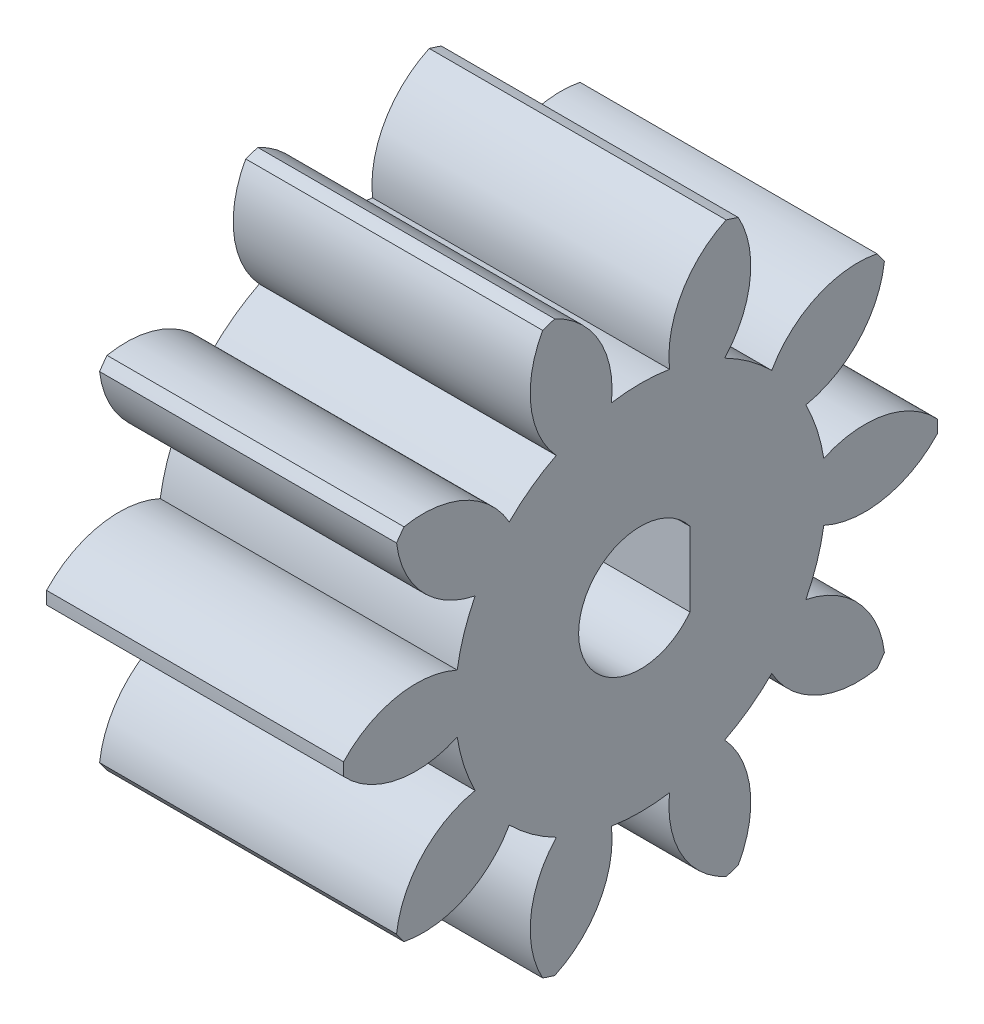
from build123d import *

# Parameters (mm, degrees)
SKETCH1_R           = 2.5
BOSS_EXTRUDE1_DEPTH = 12
BOSS_EXTRUDE2_DEPTH = 12


with BuildPart() as part:
    # Sketch1 → Boss-Extrude1 (new body)
    with BuildSketch(Plane(origin=(4.177782817, 0, 0), x_dir=(0, 0, -1), z_dir=(1, 0, 0))):
        with BuildLine():
            ThreePointArc((5.17160003, 0.862151985), (3.024281035, 2.061571734), (0.581113459, 1.777813393))
            ThreePointArc((0.581113459, 1.777813393), (0.306322633, 2.922590425), (-0.144249976, 4.010252494))
            ThreePointArc((-0.144249976, 4.010252494), (1.999103081, 5.216745044), (3.031319401, 7.449258441))
            ThreePointArc((3.031319401, 7.449258441), (2.88255375, 7.658695012), (2.729338849, 7.864899014))
            ThreePointArc((2.729338849, 7.864899014), (0.28712005, 7.573087536), (-1.522655071, 5.907464347))
            ThreePointArc((-1.522655071, 5.907464347), (-2.417848576, 6.672090425), (-3.421681197, 7.287187589))
            ThreePointArc((-3.421681197, 7.287187589), (-2.396830677, 9.523091882), (-2.873988583, 11.935954691))
            ThreePointArc((-2.873988583, 11.935954691), (-3.11744625, 12.01795018), (-3.36260338, 12.094715262))
            ThreePointArc((-3.36260338, 12.094715262), (-5.16687741, 10.423134625), (-5.651987492, 8.011858032))
            ThreePointArc((-5.651987492, 8.011858032), (-6.825650183, 8.104271984), (-7.999312874, 8.011858032))
            ThreePointArc((-7.999312874, 8.011858032), (-8.484422956, 10.423134625), (-10.288696986, 12.094715262))
            ThreePointArc((-10.288696986, 12.094715262), (-10.533854115, 12.01795018), (-10.777311783, 11.935954691))
            ThreePointArc((-10.777311783, 11.935954691), (-11.254469689, 9.523091882), (-10.229619169, 7.287187589))
            ThreePointArc((-10.229619169, 7.287187589), (-11.23345179, 6.672090425), (-12.128645295, 5.907464347))
            ThreePointArc((-12.128645295, 5.907464347), (-13.938420416, 7.573087536), (-16.380639215, 7.864899014))
            ThreePointArc((-16.380639215, 7.864899014), (-16.533854115, 7.658695012), (-16.682619767, 7.449258441))
            ThreePointArc((-16.682619767, 7.449258441), (-15.650403447, 5.216745044), (-13.50705039, 4.010252494))
            ThreePointArc((-13.50705039, 4.010252494), (-13.957622999, 2.922590425), (-14.232413825, 1.777813393))
            ThreePointArc((-14.232413825, 1.777813393), (-16.675581401, 2.061571734), (-18.822900396, 0.862151985))
            ThreePointArc((-18.822900396, 0.862151985), (-18.825650183, 0.605271984), (-18.822900396, 0.348391984))
            ThreePointArc((-18.822900396, 0.348391984), (-16.675581401, -0.851027765), (-14.232413825, -0.567269425))
            ThreePointArc((-14.232413825, -0.567269425), (-13.957622999, -1.712046456), (-13.50705039, -2.799708525))
            ThreePointArc((-13.50705039, -2.799708525), (-15.650403447, -4.006201075), (-16.682619767, -6.238714473))
            ThreePointArc((-16.682619767, -6.238714473), (-16.533854115, -6.448151043), (-16.380639215, -6.654355045))
            ThreePointArc((-16.380639215, -6.654355045), (-13.938420416, -6.362543568), (-12.128645295, -4.696920378))
            ThreePointArc((-12.128645295, -4.696920378), (-11.23345179, -5.461546456), (-10.229619169, -6.07664362))
            ThreePointArc((-10.229619169, -6.07664362), (-11.254469689, -8.312547914), (-10.777311783, -10.725410722))
            ThreePointArc((-10.777311783, -10.725410722), (-10.533854115, -10.807406211), (-10.288696986, -10.884171294))
            ThreePointArc((-10.288696986, -10.884171294), (-8.484422956, -9.212590657), (-7.999312874, -6.801314064))
            ThreePointArc((-7.999312874, -6.801314064), (-6.825650183, -6.893728016), (-5.651987492, -6.801314064))
            ThreePointArc((-5.651987492, -6.801314064), (-5.16687741, -9.212590657), (-3.36260338, -10.884171294))
            ThreePointArc((-3.36260338, -10.884171294), (-3.11744625, -10.807406211), (-2.873988583, -10.725410722))
            ThreePointArc((-2.873988583, -10.725410722), (-2.396830677, -8.312547914), (-3.421681197, -6.07664362))
            ThreePointArc((-3.421681197, -6.07664362), (-2.417848576, -5.461546456), (-1.522655071, -4.696920378))
            ThreePointArc((-1.522655071, -4.696920378), (0.28712005, -6.362543568), (2.729338849, -6.654355045))
            ThreePointArc((2.729338849, -6.654355045), (2.88255375, -6.448151043), (3.031319401, -6.238714473))
            ThreePointArc((3.031319401, -6.238714473), (1.999103081, -4.006201075), (-0.144249976, -2.799708525))
            ThreePointArc((-0.144249976, -2.799708525), (0.306322633, -1.712046456), (0.581113459, -0.567269425))
            ThreePointArc((0.581113459, -0.567269425), (3.024281035, -0.851027765), (5.17160003, 0.348391984))
            ThreePointArc((5.17160003, 0.348391984), (5.174349817, 0.605271984), (5.17160003, 0.862151985))
        make_face()
        with Locations((-6.825650183, 0.605271984)):
            Circle(SKETCH1_R, mode=Mode.SUBTRACT)
    extrude(amount=-BOSS_EXTRUDE1_DEPTH)

    # Sketch2 → Boss-Extrude2 (add)
    with BuildSketch(Plane(origin=(4.177782817, 0, 0), x_dir=(0, 0, -1), z_dir=(1, 0, 0))):
        with BuildLine():
            ThreePointArc((-4.325650183, 0.605271984), (-4.453941938, 1.395841399), (-4.825650183, 2.105271984))
            Line((-4.825650183, 2.105271984), (-4.825650183, -0.894728016))
            ThreePointArc((-4.825650183, -0.894728016), (-4.453941938, -0.185297431), (-4.325650183, 0.605271984))
        make_face()
    extrude(amount=-BOSS_EXTRUDE2_DEPTH)


solid = part.part
